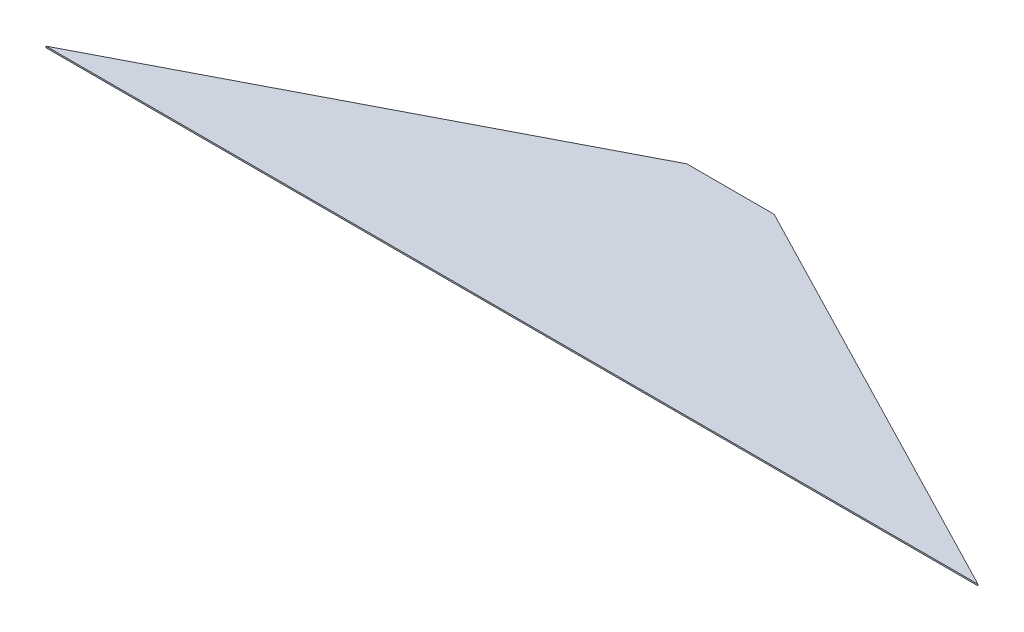
from build123d import *

# Parameters (mm, degrees)
BOSS_EXTRUDE1_DEPTH = 1


with BuildPart() as part:
    # Sketch1 → Boss-Extrude1 (new body)
    with BuildSketch(Plane(origin=(0, 0, 0), x_dir=(1, 0, 0), z_dir=(0, 1, 0))):
        Polygon((0, 0), (640, 0), (350, 150), (290, 150), align=None)
    extrude(amount=BOSS_EXTRUDE1_DEPTH)


solid = part.part
